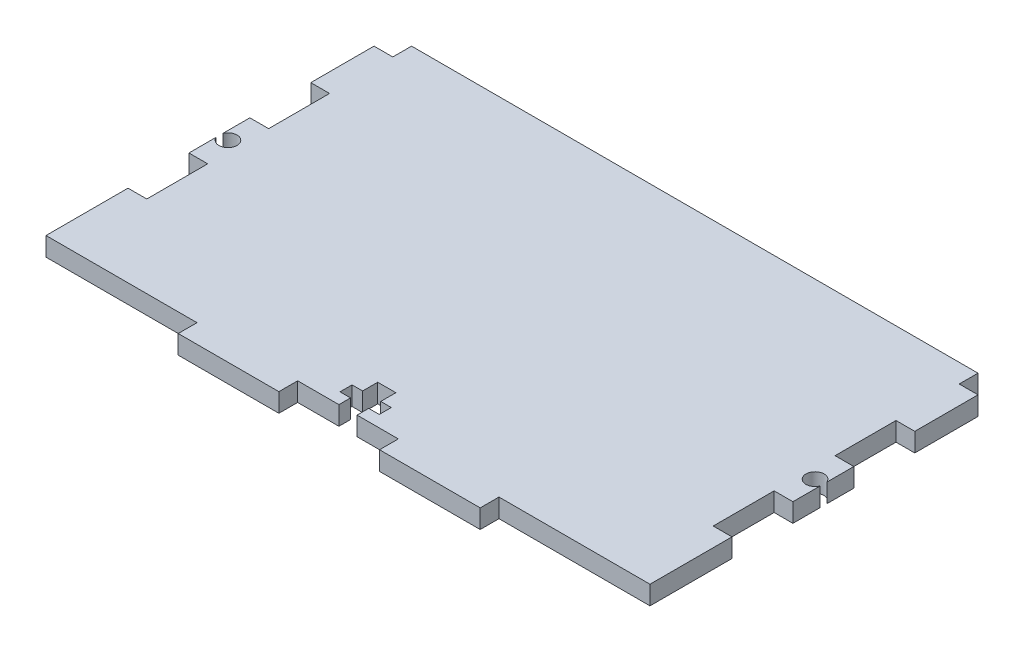
from build123d import *

# Parameters (mm, degrees)
SKETCH2_W           = 96.52
SKETCH2_H           = 55.42
BOSS_EXTRUDE1_DEPTH = 3
SKETCH3_W           = 29.21
SKETCH3_H           = 3
CUT_EXTRUDE1_DEPTH  = 3
SKETCH5_W           = 48.26
SKETCH5_H           = 3
BOSS_EXTRUDE2_DEPTH = 3
SKETCH14_W          = 16.086666666
SKETCH14_H          = 3
CUT_EXTRUDE2_DEPTH  = 3
SKETCH15_W          = 9.737913064
SKETCH15_H          = 3
BOSS_EXTRUDE9_DEPTH = 3
SKETCH26_W          = 3
SKETCH26_H          = 3
CUT_EXTRUDE4_DEPTH  = 3
CUT_EXTRUDE5_DEPTH  = 3
SKETCH29_W          = 2.9
SKETCH29_H          = 3
CUT_EXTRUDE6_DEPTH  = 6.2
SKETCH30_W          = 6.27
SKETCH30_H          = 1.926429006
CUT_EXTRUDE7_DEPTH  = 3


with BuildPart() as part:
    # Sketch2 → Boss-Extrude1 (new body)
    with BuildSketch(Plane(origin=(0, 0, 0), x_dir=(1, 0, 0), z_dir=(0, 1, 0))):
        Rectangle(SKETCH2_W, SKETCH2_H)
    extrude(amount=BOSS_EXTRUDE1_DEPTH)

    # Sketch3 → Cut-Extrude1 (cut)
    with BuildSketch(Plane.ZY.offset(48.26)):
        with Locations((0, 1.5)):
            Rectangle(SKETCH3_W, SKETCH3_H)
    cut_extrude1 = extrude(amount=-CUT_EXTRUDE1_DEPTH, mode=Mode.SUBTRACT)

    # Mirror1: Cut-Extrude1 across plane
    add(cut_extrude1.mirror(Plane(origin=(0, 0, 0), x_dir=(0, 0, 1), z_dir=(1, 0, 0))), mode=Mode.SUBTRACT)

    # Sketch5 → Boss-Extrude2 (add)
    with BuildSketch(Plane.XY.offset(27.71)):
        with Locations((0, 1.5)):
            Rectangle(SKETCH5_W, SKETCH5_H)
    extrude(amount=BOSS_EXTRUDE2_DEPTH)

    # Sketch14 → Cut-Extrude2 (cut)
    with BuildSketch(Plane.XY.offset(30.71)):
        with Locations((0, 1.5)):
            Rectangle(SKETCH14_W, SKETCH14_H)
    extrude(amount=-CUT_EXTRUDE2_DEPTH, mode=Mode.SUBTRACT)

    # Sketch15 → Boss-Extrude9 (add)
    with BuildSketch(Plane(origin=(45.26, 0, 0), x_dir=(0, 0, -1), z_dir=(1, 0, 0))):
        with Locations((0, 1.5)):
            Rectangle(SKETCH15_W, SKETCH15_H)
    boss_extrude9 = extrude(amount=BOSS_EXTRUDE9_DEPTH)

    # Mirror2: Boss-Extrude9 across plane
    add(boss_extrude9.mirror(Plane(origin=(0, 0, 0), x_dir=(0, 0, 1), z_dir=(1, 0, 0))))

    # Sketch26 → Cut-Extrude4 (cut)
    with BuildSketch(Plane(origin=(0, 0, -27.71), x_dir=(-1, 0, 0), z_dir=(0, 0, -1))):
        with Locations((-46.76, 1.5)):
            Rectangle(SKETCH26_W, SKETCH26_H)
    cut_extrude4 = extrude(amount=-CUT_EXTRUDE4_DEPTH, mode=Mode.SUBTRACT)

    # Mirror3: Cut-Extrude4 across plane
    add(cut_extrude4.mirror(Plane(origin=(0, 0, 0), x_dir=(0, 0, 1), z_dir=(1, 0, 0))), mode=Mode.SUBTRACT)

    # Sketch27 → Cut-Extrude5 (cut)
    with BuildSketch(Plane.XZ):
        with BuildLine():
            ThreePointArc((48.26, -0.546659717), (48.334780685, -0.286767695), (48.36, -0.017509454))
            ThreePointArc((48.36, -0.017509454), (48.334780685, 0.251748786), (48.26, 0.511640808))
            Line((48.26, 0.511640808), (48.26, -0.546659717))
        make_face()
        with BuildLine():
            Line((48.26, -0.546659717), (48.26, 0.511640808))
            ThreePointArc((48.26, 0.511640808), (45.46, -0.017509454), (48.26, -0.546659717))
        make_face()
    cut_extrude5 = extrude(amount=-CUT_EXTRUDE5_DEPTH, mode=Mode.SUBTRACT)

    # Mirror4: Cut-Extrude5 across plane
    add(cut_extrude5.mirror(Plane(origin=(0, 0, 0), x_dir=(0, 0, 1), z_dir=(1, 0, 0))), mode=Mode.SUBTRACT)

    # Sketch29 → Cut-Extrude6 (cut)
    with BuildSketch(Plane.XY.offset(27.71)):
        with Locations((0, 1.5)):
            Rectangle(SKETCH29_W, SKETCH29_H)
    extrude(amount=-CUT_EXTRUDE6_DEPTH, mode=Mode.SUBTRACT)

    # Sketch30 → Cut-Extrude7 (cut)
    with BuildSketch(Plane.XZ):
        with Locations((0, 24.88885073)):
            Rectangle(SKETCH30_W, SKETCH30_H)
    extrude(amount=-CUT_EXTRUDE7_DEPTH, mode=Mode.SUBTRACT)


solid = part.part
